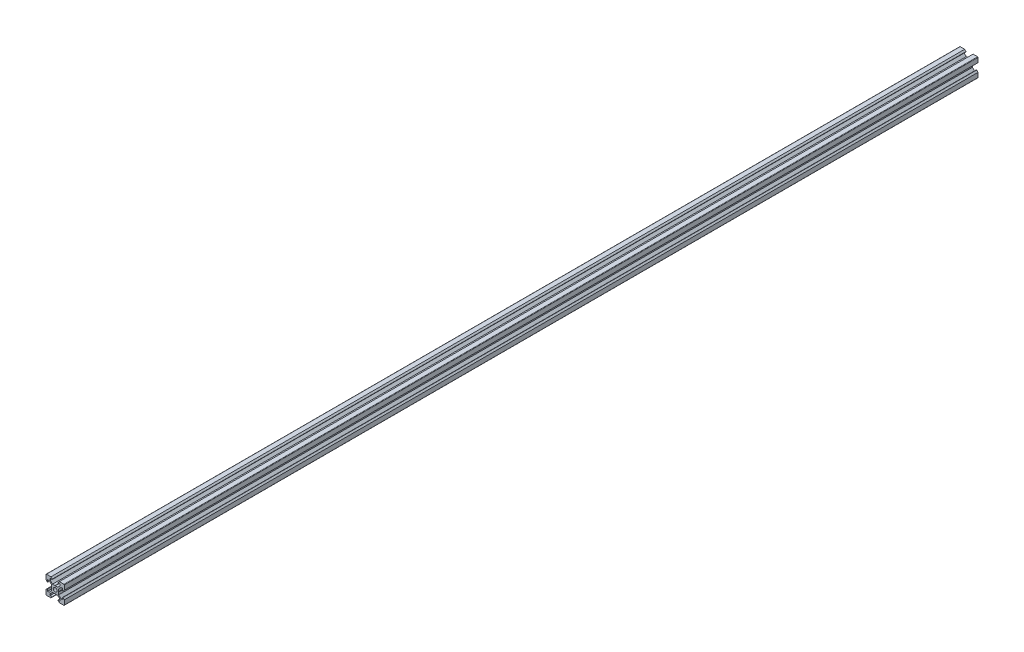
from build123d import *

# Parameters (mm, degrees)
SKETCH1_R           = 2.1
BOSS_EXTRUDE1_DEPTH = 1000


with BuildPart() as part:
    # Sketch1 → Boss-Extrude1 (new body)
    with BuildSketch(Plane.XY):
        with BuildLine():
            Line((4.58, -10), (9.5, -10))
            ThreePointArc((9.5, -10), (9.853553391, -9.853553391), (10, -9.5))
            Line((10, -9.5), (10, -4.58))
            Line((10, -4.58), (8.545, -3.125))
            Line((8.545, -3.125), (8.2, -3.125))
            Line((8.2, -3.125), (8.2, -5.5))
            Line((8.2, -5.5), (6.560660172, -5.5))
            Line((6.560660172, -5.5), (3.9, -2.839339828))
            Line((3.9, -2.839339828), (3.9, -0.21))
            Line((3.9, -0.21), (3.69, 0))
            Line((3.69, 0), (3.9, 0.21))
            Line((3.9, 0.21), (3.9, 2.839339828))
            Line((3.9, 2.839339828), (6.560660172, 5.5))
            Line((6.560660172, 5.5), (8.2, 5.5))
            Line((8.2, 5.5), (8.2, 3.125))
            Line((8.2, 3.125), (8.545, 3.125))
            Line((8.545, 3.125), (10, 4.58))
            Line((10, 4.58), (10, 9.5))
            ThreePointArc((10, 9.5), (9.853553391, 9.853553391), (9.5, 10))
            Line((9.5, 10), (4.58, 10))
            Line((4.58, 10), (3.125, 8.545))
            Line((3.125, 8.545), (3.125, 8.2))
            Line((3.125, 8.2), (5.5, 8.2))
            Line((5.5, 8.2), (5.5, 6.560660172))
            Line((5.5, 6.560660172), (2.839339828, 3.9))
            Line((2.839339828, 3.9), (0.21, 3.9))
            Line((0.21, 3.9), (0, 3.69))
            Line((0, 3.69), (-0.21, 3.9))
            Line((-0.21, 3.9), (-2.839339828, 3.9))
            Line((-2.839339828, 3.9), (-5.5, 6.560660172))
            Line((-5.5, 6.560660172), (-5.5, 8.2))
            Line((-5.5, 8.2), (-3.125, 8.2))
            Line((-3.125, 8.2), (-3.125, 8.545))
            Line((-3.125, 8.545), (-4.58, 10))
            Line((-4.58, 10), (-9.5, 10))
            ThreePointArc((-9.5, 10), (-9.853553391, 9.853553391), (-10, 9.5))
            Line((-10, 9.5), (-10, 4.58))
            Line((-10, 4.58), (-8.545, 3.125))
            Line((-8.545, 3.125), (-8.2, 3.125))
            Line((-8.2, 3.125), (-8.2, 5.5))
            Line((-8.2, 5.5), (-6.560660172, 5.5))
            Line((-6.560660172, 5.5), (-3.9, 2.839339828))
            Line((-3.9, 2.839339828), (-3.9, 0.21))
            Line((-3.9, 0.21), (-3.69, 0))
            Line((-3.69, 0), (-3.9, -0.21))
            Line((-3.9, -0.21), (-3.9, -2.839339828))
            Line((-3.9, -2.839339828), (-6.560660172, -5.5))
            Line((-6.560660172, -5.5), (-8.2, -5.5))
            Line((-8.2, -5.5), (-8.2, -3.125))
            Line((-8.2, -3.125), (-8.545, -3.125))
            Line((-8.545, -3.125), (-10, -4.58))
            Line((-10, -4.58), (-10, -9.5))
            ThreePointArc((-10, -9.5), (-9.853553391, -9.853553391), (-9.5, -10))
            Line((-9.5, -10), (-4.58, -10))
            Line((-4.58, -10), (-3.125, -8.545))
            Line((-3.125, -8.545), (-3.125, -8.2))
            Line((-3.125, -8.2), (-5.5, -8.2))
            Line((-5.5, -8.2), (-5.5, -6.560660172))
            Line((-5.5, -6.560660172), (-2.839339828, -3.9))
            Line((-2.839339828, -3.9), (-0.21, -3.9))
            Line((-0.21, -3.9), (0, -3.69))
            Line((0, -3.69), (0.21, -3.9))
            Line((0.21, -3.9), (2.839339828, -3.9))
            Line((2.839339828, -3.9), (5.5, -6.560660172))
            Line((5.5, -6.560660172), (5.5, -8.2))
            Line((5.5, -8.2), (3.125, -8.2))
            Line((3.125, -8.2), (3.125, -8.545))
            Line((3.125, -8.545), (4.58, -10))
        make_face()
        Circle(SKETCH1_R, mode=Mode.SUBTRACT)
    extrude(amount=BOSS_EXTRUDE1_DEPTH)


solid = part.part
